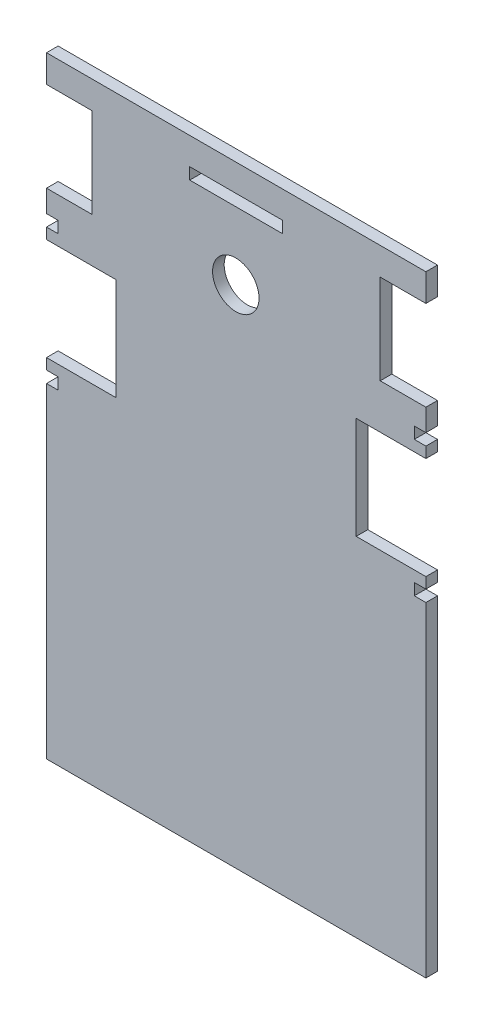
from build123d import *

# Parameters (mm, degrees)
MODEL_R                 = 6
MODEL_W                 = 24
MODEL_H                 = 3
SALIENTE_EXTRUIR1_DEPTH = 3


with BuildPart() as part:
    # Model → Saliente-Extruir1 (new body)
    with BuildSketch(Plane.XY):
        Polygon((11.392528896, 93.193403392), (11.392528896, 86.093403392), (23.192528896, 86.093403392), (23.192528896, 62.893403392), (11.392528896, 62.893403392), (11.392528896, 57.193403392), (14.392528896, 57.193403392), (14.392528896, 54.193403392), (11.392528896, 54.193403392), (11.392528896, 51.393403392), (29.392528896, 51.393403392), (29.392528896, 24.993403392), (11.392528896, 24.993403392), (11.392528896, 22.193403392), (14.392528896, 22.193403392), (14.392528896, 19.193403392), (11.392528896, 19.193403392), (11.392528896, -64.806596608), (109.392528896, -64.806596608), (109.392528896, 19.193403392), (106.392528896, 19.193403392), (106.392528896, 22.193403392), (109.392528896, 22.193403392), (109.392528896, 24.993403392), (91.392528896, 24.993403392), (91.392528896, 51.393403392), (109.392528896, 51.393403392), (109.392528896, 54.193403392), (106.392528896, 54.193403392), (106.392528896, 57.193403392), (109.392528896, 57.193403392), (109.392528896, 62.893403392), (97.592528896, 62.893403392), (97.592528896, 86.093403392), (109.392528896, 86.093403392), (109.392528896, 93.193403392), align=None)
        with Locations((60.291833129, 65.722966384)):
            Circle(MODEL_R, mode=Mode.SUBTRACT)
        with Locations((60.392528896, 84.693403392)):
            Rectangle(MODEL_W, MODEL_H, mode=Mode.SUBTRACT)
    extrude(amount=SALIENTE_EXTRUIR1_DEPTH)


solid = part.part
